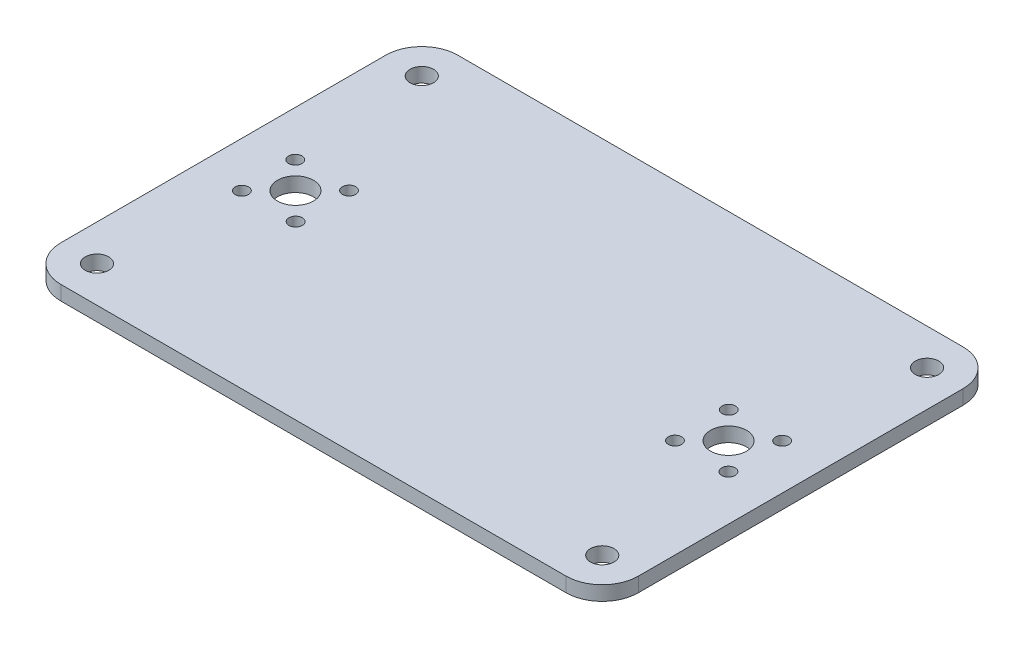
from build123d import *

# Parameters (mm, degrees)
SKETCH_1_R      = 5
SKETCH_1_R_2    = 1.85
SKETCH_1_R_3    = 3.25
EXTRUDE_1_DEPTH = 4


with BuildPart() as part:
    # Эскиз1 → Бобышка-Вытянуть1 (new body)
    with BuildSketch(Plane(origin=(0, 0, 0), x_dir=(1, 0, 0), z_dir=(0, 1, 0))):
        with BuildLine():
            Line((70, -55), (-70, -55))
            ThreePointArc((-70, -55), (-77.071067812, -52.071067812), (-80, -45))
            Line((-80, -45), (-80, 45))
            ThreePointArc((-80, 45), (-77.071067812, 52.071067812), (-70, 55))
            Line((-70, 55), (70, 55))
            ThreePointArc((70, 55), (77.071067812, 52.071067812), (80, 45))
            Line((80, 45), (80, -45))
            ThreePointArc((80, -45), (77.071067812, -52.071067812), (70, -55))
        make_face()
        with Locations((-60, 0)):
            Circle(SKETCH_1_R, mode=Mode.SUBTRACT)
        with Locations((-67.446640333, 7.402536575)):
            Circle(SKETCH_1_R_2, mode=Mode.SUBTRACT)
        with Locations((-52.597463425, 7.446640333)):
            Circle(SKETCH_1_R_2, mode=Mode.SUBTRACT)
        with Locations((-52.553359667, -7.402536575)):
            Circle(SKETCH_1_R_2, mode=Mode.SUBTRACT)
        with Locations((-67.402536575, -7.446640333)):
            Circle(SKETCH_1_R_2, mode=Mode.SUBTRACT)
        with Locations((52.597463425, 7.446640333)):
            Circle(SKETCH_1_R_2, mode=Mode.SUBTRACT)
        with Locations((52.553359667, -7.402536575)):
            Circle(SKETCH_1_R_2, mode=Mode.SUBTRACT)
        with Locations((67.402536575, -7.446640333)):
            Circle(SKETCH_1_R_2, mode=Mode.SUBTRACT)
        with Locations((60, 0)):
            Circle(SKETCH_1_R, mode=Mode.SUBTRACT)
        with Locations((67.446640333, 7.402536575)):
            Circle(SKETCH_1_R_2, mode=Mode.SUBTRACT)
        with Locations((-70, 45)):
            Circle(SKETCH_1_R_3, mode=Mode.SUBTRACT)
        with Locations((-70, -45)):
            Circle(SKETCH_1_R_3, mode=Mode.SUBTRACT)
        with Locations((70, -45)):
            Circle(SKETCH_1_R_3, mode=Mode.SUBTRACT)
        with Locations((70, 45)):
            Circle(SKETCH_1_R_3, mode=Mode.SUBTRACT)
    extrude(amount=EXTRUDE_1_DEPTH)


solid = part.part
